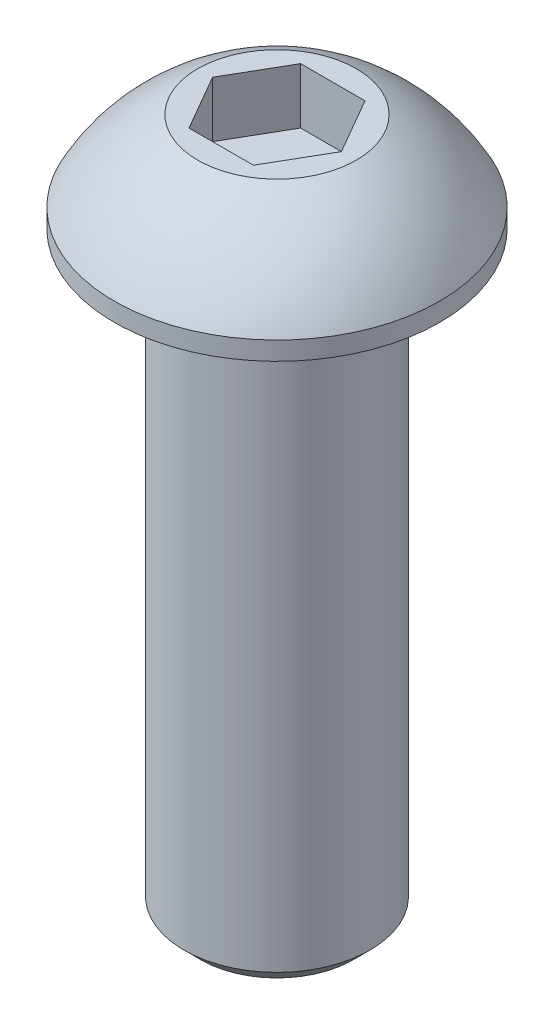
from build123d import *

# Parameters (mm, degrees)
CUT_EXTRUDE1_DEPTH = 2.38125


with BuildPart() as part:
    # Sketch1 → Base-Revolve (revolve)
    with BuildSketch(Plane.XY):
        with BuildLine():
            Line((0, -25.4), (3.263194444, -25.4))
            Line((3.263194444, -25.4), (3.96875, -24.694444444))
            Line((3.96875, -24.694444444), (3.96875, 0))
            Line((3.96875, 0), (6.9469, 0))
            Line((6.9469, 0), (6.9469, 0.7874))
            ThreePointArc((6.9469, 0.7874), (5.442852348, 2.789756108), (3.384630657, 4.2164))
            Line((3.384630657, 4.2164), (0, 4.2164))
            Line((0, 4.2164), (0, -25.4))
        make_face()
    revolve(axis=Axis((0, 69.088, 0), (0, -1, 0)))

    # Sketch2 → Cut-Extrude1 (cut)
    with BuildSketch(Plane(origin=(0, 4.2164, 0), x_dir=(-1, 0, 0), z_dir=(0, 1, 0))):
        Polygon((-2.749630657, 0), (-1.374815329, -2.38125), (1.374815329, -2.38125), (2.749630657, 0), (1.374815329, 2.38125), (-1.374815329, 2.38125), align=None)
    extrude(amount=-CUT_EXTRUDE1_DEPTH, mode=Mode.SUBTRACT)


solid = part.part
